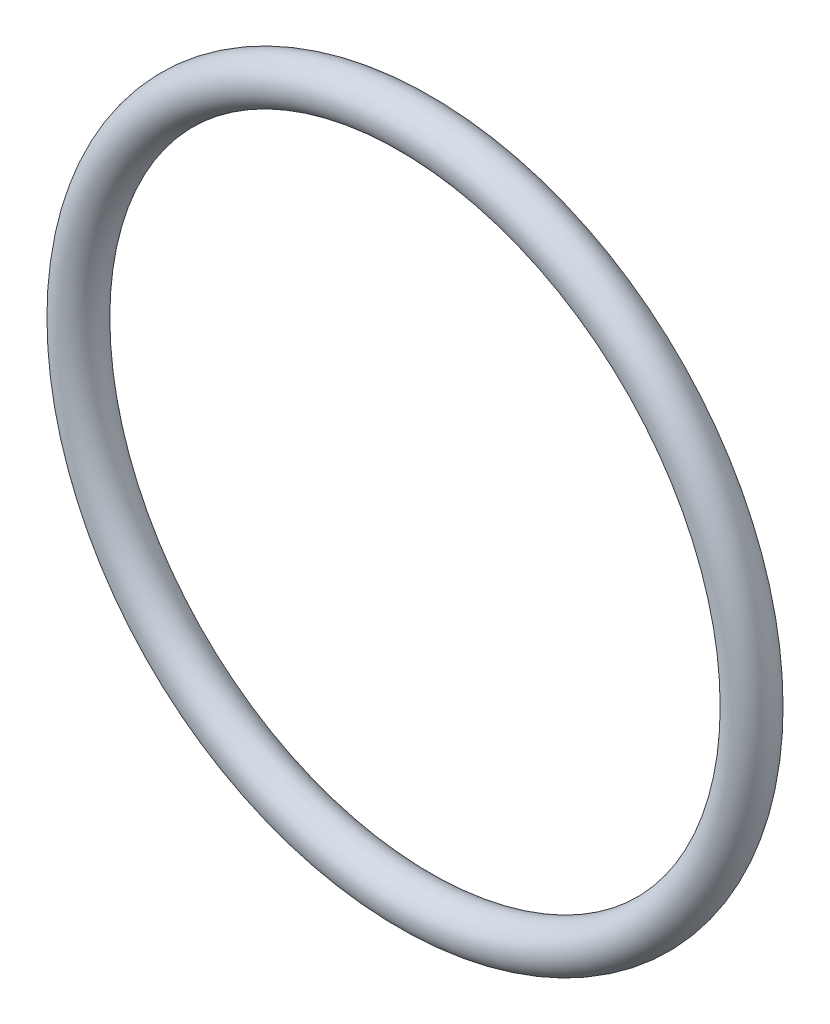
from build123d import *

# Parameters (mm, degrees)
SKETCH1_R = 0.889


with BuildPart() as part:
    # Sketch1 → Revolve1 (revolve)
    with BuildSketch(Plane(origin=(0, 0, 0), x_dir=(0, -1, 0), z_dir=(1, 0, 0))):
        with Locations((13.4493, 0)):
            Circle(SKETCH1_R)
    revolve(axis=Axis((0, 0, 0.889), (0, 0, -1)))


solid = part.part
